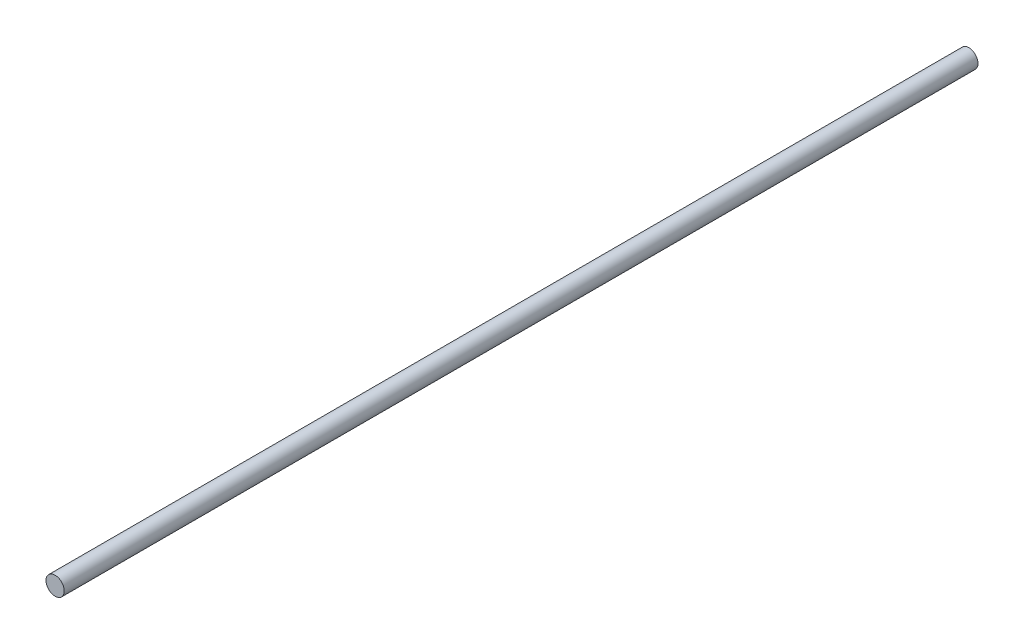
from build123d import *

# Parameters (mm, degrees)
SKETCH2_R           = 3.048
BOSS_EXTRUDE1_DEPTH = 304.8


with BuildPart() as part:
    # Sketch2 → Boss-Extrude1 (new body)
    with BuildSketch(Plane.XY):
        Circle(SKETCH2_R)
    extrude(amount=BOSS_EXTRUDE1_DEPTH)


solid = part.part
